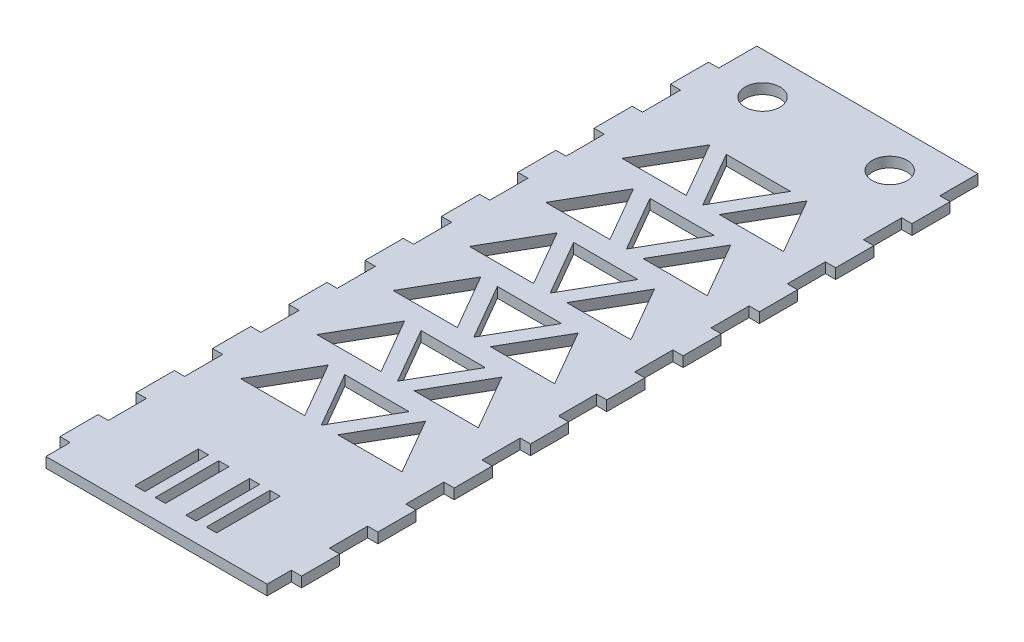
from build123d import *

# Parameters (mm, degrees)
SKETCH1_W               = 76
SKETCH1_H               = 223.60679775
BOSS_EXTRUDE1_DEPTH     = 1.61
SKETCH2_W               = 3.22
SKETCH2_H               = 12
CUT_EXTRUDE1_DEPTH      = 3.22
LPATTERN1_COUNT         = 10
LPATTERN1_PITCH         = 24
MIRROR1_COPY_1_SKETCH_W = 3.22
MIRROR1_COPY_1_SKETCH_H = 12
MIRROR1_COPY_1_DEPTH    = 3.22
MIRROR1_COPY_2_SKETCH_W = 3.22
MIRROR1_COPY_2_SKETCH_H = 12
MIRROR1_COPY_2_DEPTH    = 3.22
MIRROR1_COPY_3_SKETCH_W = 3.22
MIRROR1_COPY_3_SKETCH_H = 12
MIRROR1_COPY_3_DEPTH    = 3.22
MIRROR1_COPY_4_SKETCH_W = 3.22
MIRROR1_COPY_4_SKETCH_H = 12
MIRROR1_COPY_4_DEPTH    = 3.22
MIRROR1_COPY_5_SKETCH_W = 3.22
MIRROR1_COPY_5_SKETCH_H = 12
MIRROR1_COPY_5_DEPTH    = 3.22
MIRROR1_COPY_6_SKETCH_W = 3.22
MIRROR1_COPY_6_SKETCH_H = 12
MIRROR1_COPY_6_DEPTH    = 3.22
MIRROR1_COPY_7_SKETCH_W = 3.22
MIRROR1_COPY_7_SKETCH_H = 12
MIRROR1_COPY_7_DEPTH    = 3.22
MIRROR1_COPY_8_SKETCH_W = 3.22
MIRROR1_COPY_8_SKETCH_H = 12
MIRROR1_COPY_8_DEPTH    = 3.22
MIRROR1_COPY_9_SKETCH_W = 3.22
MIRROR1_COPY_9_SKETCH_H = 12
MIRROR1_COPY_9_DEPTH    = 3.22
SKETCH4_R               = 5.5
CUT_EXTRUDE2_DEPTH      = 10
CUT_EXTRUDE5_REACH      = 5.22
SKETCH7_W               = 3.22
SKETCH7_H               = 20
CUT_EXTRUDE7_DEPTH      = 3.22
LPATTERN2_COUNT         = 6
LPATTERN2_PITCH         = 24


with BuildPart() as part:
    # Sketch1 → Boss-Extrude1 (new body, symmetric)
    with BuildSketch(Plane(origin=(0, 0, 0), x_dir=(1, 0, 0), z_dir=(0, 1, 0))):
        Rectangle(SKETCH1_W, SKETCH1_H)
    extrude(amount=BOSS_EXTRUDE1_DEPTH, both=True)

    # Sketch2 → Cut-Extrude1 (cut)
    with BuildSketch(Plane(origin=(0, 1.61, 0), x_dir=(1, 0, 0), z_dir=(0, 1, 0))):
        with Locations((36.39, 105.803398875)):
            Rectangle(SKETCH2_W, SKETCH2_H)
    cut_extrude1 = extrude(amount=-CUT_EXTRUDE1_DEPTH, mode=Mode.SUBTRACT)

    # LPattern1: Cut-Extrude1 ×10
    with Locations(*[(0, 0, i * LPATTERN1_PITCH) for i in range(1, LPATTERN1_COUNT)]):
        add(cut_extrude1, mode=Mode.SUBTRACT)

    # Mirror1: Cut-Extrude1 across plane
    add(cut_extrude1.mirror(Plane(origin=(0, 0, 0), x_dir=(0, 0, 1), z_dir=(1, 0, 0))), mode=Mode.SUBTRACT)

    # Mirror1 copy 1 sketch → Mirror1 copy 1 (cut)
    with BuildSketch(Plane(origin=(0, 1.61, 24), x_dir=(-1, 0, 0), z_dir=(0, 1, 0))):
        with Locations((36.39, -105.803398875)):
            Rectangle(MIRROR1_COPY_1_SKETCH_W, MIRROR1_COPY_1_SKETCH_H)
    extrude(amount=-MIRROR1_COPY_1_DEPTH, mode=Mode.SUBTRACT)

    # Mirror1 copy 2 sketch → Mirror1 copy 2 (cut)
    with BuildSketch(Plane(origin=(0, 1.61, 48), x_dir=(-1, 0, 0), z_dir=(0, 1, 0))):
        with Locations((36.39, -105.803398875)):
            Rectangle(MIRROR1_COPY_2_SKETCH_W, MIRROR1_COPY_2_SKETCH_H)
    extrude(amount=-MIRROR1_COPY_2_DEPTH, mode=Mode.SUBTRACT)

    # Mirror1 copy 3 sketch → Mirror1 copy 3 (cut)
    with BuildSketch(Plane(origin=(0, 1.61, 72), x_dir=(-1, 0, 0), z_dir=(0, 1, 0))):
        with Locations((36.39, -105.803398875)):
            Rectangle(MIRROR1_COPY_3_SKETCH_W, MIRROR1_COPY_3_SKETCH_H)
    extrude(amount=-MIRROR1_COPY_3_DEPTH, mode=Mode.SUBTRACT)

    # Mirror1 copy 4 sketch → Mirror1 copy 4 (cut)
    with BuildSketch(Plane(origin=(0, 1.61, 96), x_dir=(-1, 0, 0), z_dir=(0, 1, 0))):
        with Locations((36.39, -105.803398875)):
            Rectangle(MIRROR1_COPY_4_SKETCH_W, MIRROR1_COPY_4_SKETCH_H)
    extrude(amount=-MIRROR1_COPY_4_DEPTH, mode=Mode.SUBTRACT)

    # Mirror1 copy 5 sketch → Mirror1 copy 5 (cut)
    with BuildSketch(Plane(origin=(0, 1.61, 120), x_dir=(-1, 0, 0), z_dir=(0, 1, 0))):
        with Locations((36.39, -105.803398875)):
            Rectangle(MIRROR1_COPY_5_SKETCH_W, MIRROR1_COPY_5_SKETCH_H)
    extrude(amount=-MIRROR1_COPY_5_DEPTH, mode=Mode.SUBTRACT)

    # Mirror1 copy 6 sketch → Mirror1 copy 6 (cut)
    with BuildSketch(Plane(origin=(0, 1.61, 144), x_dir=(-1, 0, 0), z_dir=(0, 1, 0))):
        with Locations((36.39, -105.803398875)):
            Rectangle(MIRROR1_COPY_6_SKETCH_W, MIRROR1_COPY_6_SKETCH_H)
    extrude(amount=-MIRROR1_COPY_6_DEPTH, mode=Mode.SUBTRACT)

    # Mirror1 copy 7 sketch → Mirror1 copy 7 (cut)
    with BuildSketch(Plane(origin=(0, 1.61, 168), x_dir=(-1, 0, 0), z_dir=(0, 1, 0))):
        with Locations((36.39, -105.803398875)):
            Rectangle(MIRROR1_COPY_7_SKETCH_W, MIRROR1_COPY_7_SKETCH_H)
    extrude(amount=-MIRROR1_COPY_7_DEPTH, mode=Mode.SUBTRACT)

    # Mirror1 copy 8 sketch → Mirror1 copy 8 (cut)
    with BuildSketch(Plane(origin=(0, 1.61, 192), x_dir=(-1, 0, 0), z_dir=(0, 1, 0))):
        with Locations((36.39, -105.803398875)):
            Rectangle(MIRROR1_COPY_8_SKETCH_W, MIRROR1_COPY_8_SKETCH_H)
    extrude(amount=-MIRROR1_COPY_8_DEPTH, mode=Mode.SUBTRACT)

    # Mirror1 copy 9 sketch → Mirror1 copy 9 (cut)
    with BuildSketch(Plane(origin=(0, 1.61, 216), x_dir=(-1, 0, 0), z_dir=(0, 1, 0))):
        with Locations((36.39, -105.803398875)):
            Rectangle(MIRROR1_COPY_9_SKETCH_W, MIRROR1_COPY_9_SKETCH_H)
    extrude(amount=-MIRROR1_COPY_9_DEPTH, mode=Mode.SUBTRACT)

    # Sketch4 → Cut-Extrude2 (cut)
    with BuildSketch(Plane.XZ.offset(1.61)):
        with Locations((-20, -98.803398875)):
            Circle(SKETCH4_R)
        with Locations((20, -98.803398875)):
            Circle(SKETCH4_R)
    extrude(amount=-CUT_EXTRUDE2_DEPTH, mode=Mode.SUBTRACT)

    # Sketch7 → Cut-Extrude5 (cut, up to next)
    with BuildSketch(Plane.XZ.offset(1.61), mode=Mode.PRIVATE) as cut_extrude5_sk1:
        with Locations((-11.27, 95.803398875)):
            Rectangle(SKETCH7_W, SKETCH7_H)
    cut_extrude5_tool1 = extrude(cut_extrude5_sk1.sketch, amount=-CUT_EXTRUDE5_REACH, mode=Mode.PRIVATE) & part.part
    add(cut_extrude5_tool1.solids().sort_by_distance((-11.27, -1.61, 95.803399))[0], mode=Mode.SUBTRACT)
    # Sketch7 → Cut-Extrude5 (cut, up to next)
    with BuildSketch(Plane.XZ.offset(1.61), mode=Mode.PRIVATE) as cut_extrude5_sk2:
        with Locations((-4.83, 95.803398875)):
            Rectangle(SKETCH7_W, SKETCH7_H)
    cut_extrude5_tool2 = extrude(cut_extrude5_sk2.sketch, amount=-CUT_EXTRUDE5_REACH, mode=Mode.PRIVATE) & part.part
    add(cut_extrude5_tool2.solids().sort_by_distance((-4.83, -1.61, 95.803399))[0], mode=Mode.SUBTRACT)
    # Sketch7 → Cut-Extrude5 (cut, up to next)
    with BuildSketch(Plane.XZ.offset(1.61), mode=Mode.PRIVATE) as cut_extrude5_sk3:
        with Locations((4.83, 95.803398875)):
            Rectangle(SKETCH7_W, SKETCH7_H)
    cut_extrude5_tool3 = extrude(cut_extrude5_sk3.sketch, amount=-CUT_EXTRUDE5_REACH, mode=Mode.PRIVATE) & part.part
    add(cut_extrude5_tool3.solids().sort_by_distance((4.83, -1.61, 95.803399))[0], mode=Mode.SUBTRACT)
    # Sketch7 → Cut-Extrude5 (cut, up to next)
    with BuildSketch(Plane.XZ.offset(1.61), mode=Mode.PRIVATE) as cut_extrude5_sk4:
        with Locations((11.27, 95.803398875)):
            Rectangle(SKETCH7_W, SKETCH7_H)
    cut_extrude5_tool4 = extrude(cut_extrude5_sk4.sketch, amount=-CUT_EXTRUDE5_REACH, mode=Mode.PRIVATE) & part.part
    add(cut_extrude5_tool4.solids().sort_by_distance((11.27, -1.61, 95.803399))[0], mode=Mode.SUBTRACT)

    # Sketch8 → Cut-Extrude7 (cut)
    with BuildSketch(Plane(origin=(0, 1.61, 0), x_dir=(1, 0, 0), z_dir=(0, 1, 0))):
        Polygon((-5.2, 60), (-15.303629711, 77.5), (-25.407259422, 60), align=None)
        Polygon((-10.103629711, 77.5), (10.103629711, 77.5), (0, 60), align=None)
        Polygon((15.303629711, 77.5), (25.407259422, 60), (5.2, 60), align=None)
    cut_extrude7 = extrude(amount=-CUT_EXTRUDE7_DEPTH, mode=Mode.SUBTRACT)

    # LPattern2: Cut-Extrude7 ×6
    with Locations(*[(0, 0, i * LPATTERN2_PITCH) for i in range(1, LPATTERN2_COUNT)]):
        add(cut_extrude7, mode=Mode.SUBTRACT)


solid = part.part
